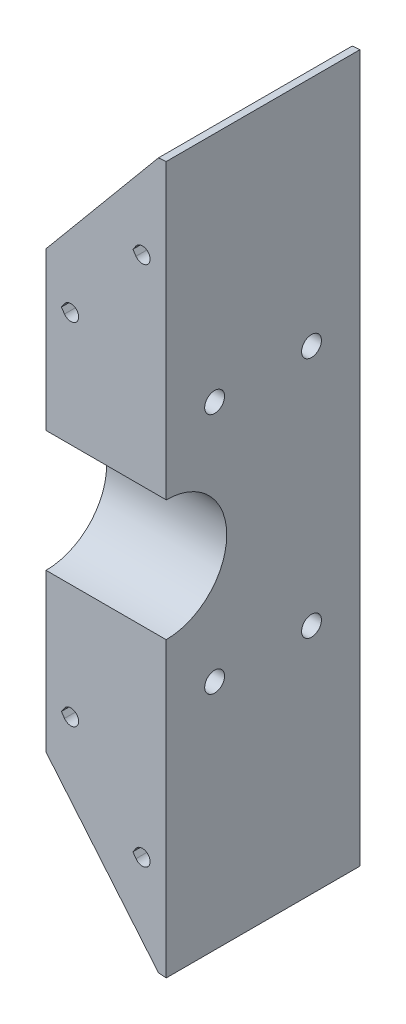
from build123d import *
from OCP.BRepFilletAPI import BRepFilletAPI_MakeChamfer

# Parameters (mm, degrees)
BOSS_EXTRUDE1_DEPTH = 40
SKETCH2_R           = 2.05
CUT_EXTRUDE1_DEPTH  = 89.340803709
SKETCH2_4_R         = 4
SKETCH2_4_R_2       = 2.05
CUT_EXTRUDE2_DEPTH  = 6
CHAMFER1_SIZE       = 2.5
CHAMFER1_SIZE2      = 1.775056745
SKETCH3_W           = 5.5
SKETCH3_H           = 5.5
CUT_EXTRUDE3_DEPTH  = 5


with BuildPart() as part:
    # Sketch1 → Boss-Extrude1 (new body)
    with BuildSketch(Plane(origin=(0, 0, 0), x_dir=(0, 1, 0), z_dir=(0, 0, 1))):
        Polygon((-45, 25), (45, 25), (74.76, 0.2), (-74.76, 0.2), align=None)
        with BuildLine():
            Line((-54.771952061, 6.432118468), (-53.854229763, 7.074714539))
            Line((-53.854229763, 7.074714539), (-52.936507465, 6.432118468))
            ThreePointArc((-52.936507465, 6.432118468), (-53.854229763, 3.521475197), (-54.771952061, 6.432118468))
        make_face(mode=Mode.SUBTRACT)
        with BuildLine():
            Line((-37.063492535, 21.189168074), (-36.145770237, 21.831764145))
            Line((-36.145770237, 21.831764145), (-35.228047939, 21.189168074))
            ThreePointArc((-35.228047939, 21.189168074), (-36.145770237, 18.278524803), (-37.063492535, 21.189168074))
        make_face(mode=Mode.SUBTRACT)
        with BuildLine():
            Line((35.228047939, 21.189168074), (36.145770237, 21.831764145))
            Line((36.145770237, 21.831764145), (37.063492535, 21.189168074))
            ThreePointArc((37.063492535, 21.189168074), (36.145770237, 18.278524803), (35.228047939, 21.189168074))
        make_face(mode=Mode.SUBTRACT)
        with BuildLine():
            Line((52.936507465, 6.432118468), (53.854229763, 7.074714539))
            Line((53.854229763, 7.074714539), (54.771952061, 6.432118468))
            ThreePointArc((54.771952061, 6.432118468), (53.854229763, 3.521475197), (52.936507465, 6.432118468))
        make_face(mode=Mode.SUBTRACT)
    extrude(amount=-BOSS_EXTRUDE1_DEPTH)

    # Sketch2 → Cut-Extrude1 (cut, through all)
    with BuildSketch(Plane(origin=(-25, 0, 0), x_dir=(0, -1, 0), z_dir=(-1, 0, 0))):
        with BuildLine():
            Line((12.5, 0), (-12.5, 0))
            ThreePointArc((-12.5, 0), (0, -12.5), (12.5, 0))
        make_face()
        with Locations((-25, -30)):
            Circle(SKETCH2_R)
        with Locations((-25, -10)):
            Circle(SKETCH2_R)
        with Locations((25, -10)):
            Circle(SKETCH2_R)
        with Locations((25, -30)):
            Circle(SKETCH2_R)
    extrude(amount=-CUT_EXTRUDE1_DEPTH, mode=Mode.SUBTRACT)

    # Sketch2_4 → Cut-Extrude2 (cut)
    # profile 1 of 5: a face of its own
    with BuildSketch(Plane(origin=(-25, 0, 0), x_dir=(0, -1, 0), z_dir=(-1, 0, 0))):
        with Locations((-25, -10)):
            Circle(SKETCH2_4_R)
        with Locations((-25, -10)):
            Circle(SKETCH2_4_R_2, mode=Mode.SUBTRACT)
    # profile 2 of 5: a face of its own
    with BuildSketch(Plane(origin=(-25, 0, 0), x_dir=(0, -1, 0), z_dir=(-1, 0, 0))):
        with Locations((-25, -30)):
            Circle(SKETCH2_4_R)
        with Locations((-25, -30)):
            Circle(SKETCH2_4_R_2, mode=Mode.SUBTRACT)
    # profile 3 of 5: a face of its own
    with BuildSketch(Plane(origin=(-25, 0, 0), x_dir=(0, -1, 0), z_dir=(-1, 0, 0))):
        with Locations((25, -10)):
            Circle(SKETCH2_4_R)
        with Locations((25, -10)):
            Circle(SKETCH2_4_R_2, mode=Mode.SUBTRACT)
    # profile 4 of 5: a face of its own
    with BuildSketch(Plane(origin=(-25, 0, 0), x_dir=(0, -1, 0), z_dir=(-1, 0, 0))):
        with Locations((25, -30)):
            Circle(SKETCH2_4_R)
        with Locations((25, -30)):
            Circle(SKETCH2_4_R_2, mode=Mode.SUBTRACT)
    # profile 5 of 5: a face of its own
    with BuildSketch(Plane(origin=(-25, 0, 0), x_dir=(0, -1, 0), z_dir=(-1, 0, 0))):
        with BuildLine():
            Line((-12.5, 0), (12.5, 0))
            ThreePointArc((12.5, 0), (0, -12.5), (-12.5, 0))
        make_face()
    extrude(amount=-CUT_EXTRUDE2_DEPTH, mode=Mode.SUBTRACT)

    # Chamfer1: one chamfer whose edges measure the first distance from different faces: ONE call of the kernel's chamfer builder (chamfer() names one face for all edges)
    chamfer1_edges_1 = [part.edges().sort_by_distance(p)[0] for p in [
        (-0.2, -74.76, -20),
    ]]
    chamfer1_side_1 = [part.faces().sort_by_distance(p)[0] for p in [
        (-12.6, -59.88, -20),
    ]]
    chamfer1_edges_2 = [part.edges().sort_by_distance(p)[0] for p in [
        (-0.2, 74.76, -20),
    ]]
    chamfer1_side_2 = [part.faces().sort_by_distance(p)[0] for p in [
        (-12.6, 59.88, -20),
    ]]
    chamfer1 = BRepFilletAPI_MakeChamfer(part.part.solid().wrapped)
    for e in chamfer1_edges_1:
        chamfer1.Add(CHAMFER1_SIZE, CHAMFER1_SIZE2, e.wrapped, chamfer1_side_1[0].wrapped)  # the first distance lies on this face
    for e in chamfer1_edges_2:
        chamfer1.Add(CHAMFER1_SIZE, CHAMFER1_SIZE2, e.wrapped, chamfer1_side_2[0].wrapped)  # the first distance lies on this face
    add(Compound.cast(chamfer1.Shape()), mode=Mode.REPLACE)

    # Sketch3 → Cut-Extrude3 (cut)
    with BuildSketch(Plane(origin=(0, 0, -40), x_dir=(1, 0, 0), z_dir=(0, 0, -1))):
        with Locations((-19.878524803, 36.145770237)):
            Rectangle(SKETCH3_W, SKETCH3_H)
        with Locations((-5.121475197, 53.854229763)):
            Rectangle(SKETCH3_W, SKETCH3_H)
        with Locations((-19.878524803, -36.145770237)):
            Rectangle(SKETCH3_W, SKETCH3_H)
        with Locations((-5.121475197, -53.854229763)):
            Rectangle(SKETCH3_W, SKETCH3_H)
    extrude(amount=-CUT_EXTRUDE3_DEPTH, mode=Mode.SUBTRACT)


solid = part.part
